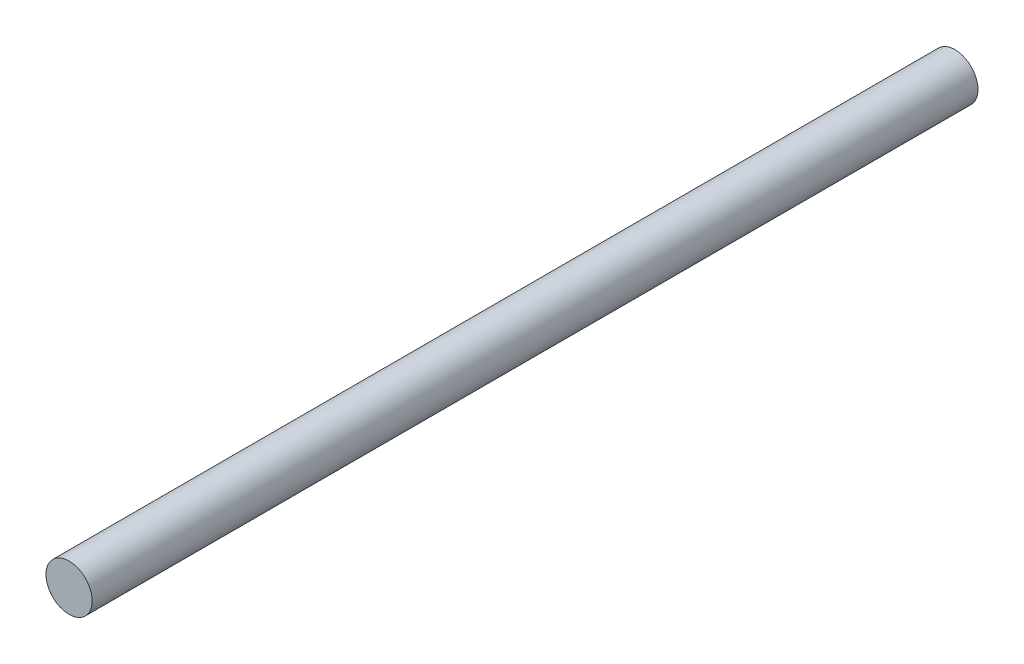
from build123d import *

# Parameters (mm, degrees)
SKETCH1_R           = 0.5
BOSS_EXTRUDE1_DEPTH = 19.17


with BuildPart() as part:
    # Sketch1 → Boss-Extrude1 (new body)
    with BuildSketch(Plane.XY):
        Circle(SKETCH1_R)
    extrude(amount=BOSS_EXTRUDE1_DEPTH)


solid = part.part
